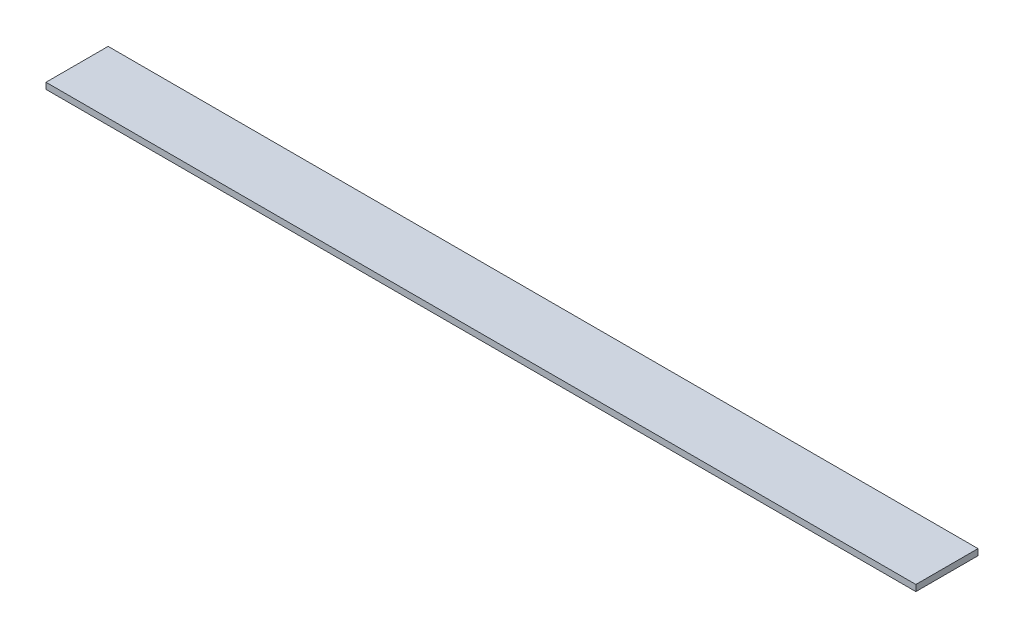
from build123d import *

# Parameters (mm, degrees)
ESQUISSE1_W      = 1400
ESQUISSE1_H      = 100
EXTRUSION1_DEPTH = 10


with BuildPart() as part:
    # Esquisse1 → Extrusion1 (new body)
    with BuildSketch(Plane(origin=(0, 0, 0), x_dir=(1, 0, 0), z_dir=(0, 1, 0))):
        with Locations((700, 50)):
            Rectangle(ESQUISSE1_W, ESQUISSE1_H)
    extrude(amount=EXTRUSION1_DEPTH)


solid = part.part
